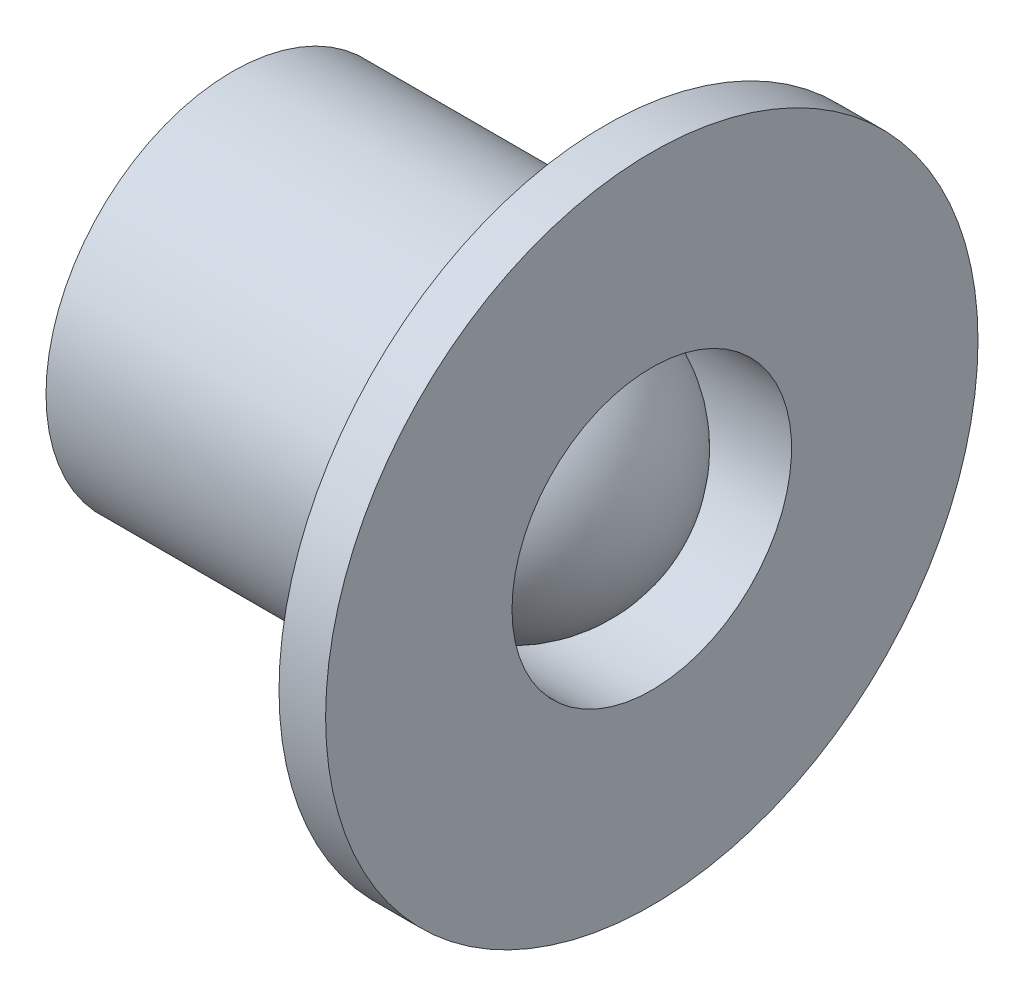
from build123d import *


with BuildPart() as part:
    # Esquisse1 → Révolution1 (revolve)
    with BuildSketch(Plane.XY, mode=Mode.PRIVATE) as r_volution1_sk:
        with BuildLine():
            Line((0, 1.5), (0, 3.5))
            Line((0, 3.5), (-0.5, 3.5))
            Line((-0.5, 3.5), (-0.5, 2))
            Line((-0.5, 2), (-4.5, 2))
            Line((-4.5, 2), (-4.5, 0))
            Line((-4.5, 0), (0, 0))
            ThreePointArc((0, 0), (-0.439339828, 1.060660172), (-1.5, 1.5))
            Line((-1.5, 1.5), (0, 1.5))
        make_face()
    revolve(r_volution1_sk.sketch.rotate(Axis((0, 0, 0), (1, 0, 0)), 90), axis=Axis((0, 0, 0), (1, 0, 0)))  # turned: the seam where the file's is


solid = part.part
